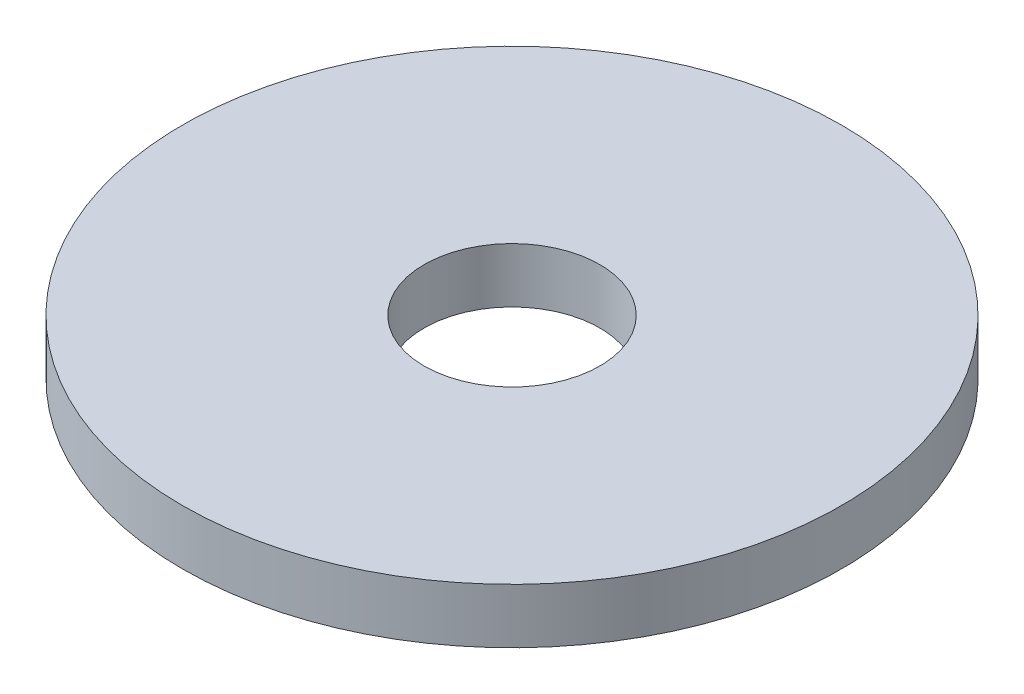
from build123d import *

# Parameters (mm, degrees)
SKETCH_1_R      = 6
SKETCH_1_R_2    = 1.6
EXTRUDE_1_DEPTH = 1


with BuildPart() as part:
    # 草图1 → 凸台-拉伸1 (new body)
    with BuildSketch(Plane(origin=(0, 0, 0), x_dir=(1, 0, 0), z_dir=(0, 1, 0))):
        Circle(SKETCH_1_R)
        Circle(SKETCH_1_R_2, mode=Mode.SUBTRACT)
    extrude(amount=EXTRUDE_1_DEPTH)


solid = part.part
